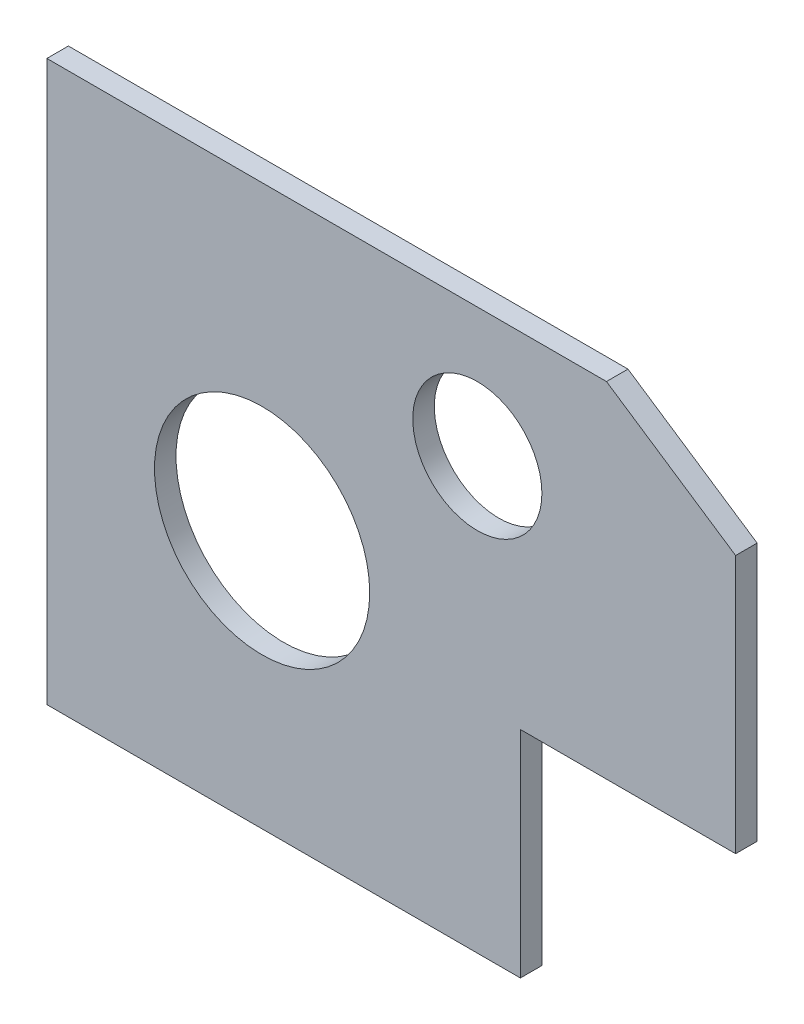
from build123d import *

# Parameters (mm, degrees)
SKETCH1_R           = 19.05
SKETCH1_R_2         = 31.75
BOSS_EXTRUDE1_DEPTH = 6.35


with BuildPart() as part:
    # Sketch1 → Boss-Extrude1 (new body)
    with BuildSketch(Plane.XY):
        Polygon((0, 63.5), (-63.5, 63.5), (-63.5, 0), (-203.2, 0), (-203.2, 165.1), (-38.1, 165.1), (0, 139.7), align=None)
        with Locations((-76.2, 127)):
            Circle(SKETCH1_R, mode=Mode.SUBTRACT)
        with Locations((-139.7, 76.2)):
            Circle(SKETCH1_R_2, mode=Mode.SUBTRACT)
    extrude(amount=BOSS_EXTRUDE1_DEPTH)


solid = part.part
